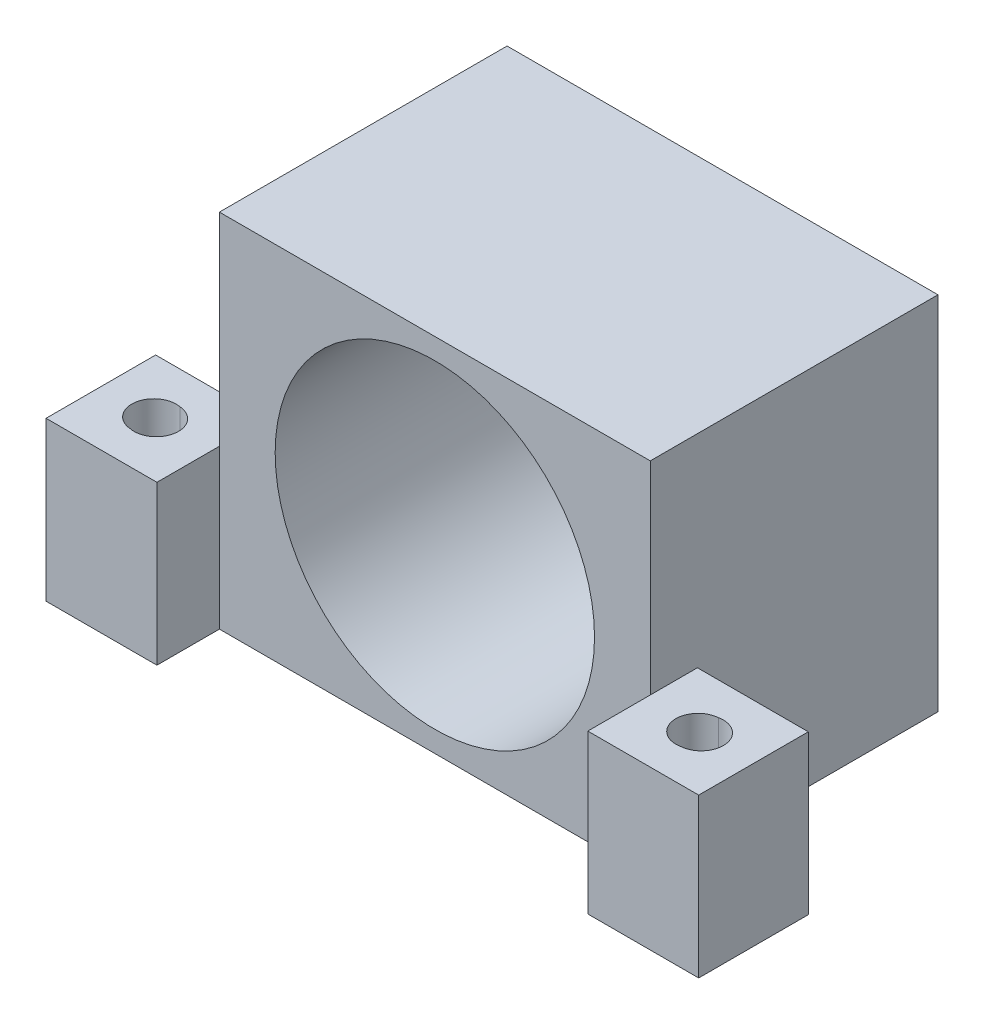
from build123d import *

# Parameters (mm, degrees)
SKETCH1_W                = 34
SKETCH1_H                = 28.5
BOSS_EXTRUDE1_DEPTH      = 22.7
SKETCH3_R                = 12.6
CUT_EXTRUDE1_DEPTH       = 21
SKETCH5_R                = 1.625
SKETCH5_R_2              = 3.75
CUT_EXTRUDE2_DEPTH       = 31.546071761
BOSS_EXTRUDE2_DEPTH      = 4.93
BOSS_EXTRUDE2_DEPTH_BACK = 3.72
SKETCH7_W                = 8.75
SKETCH7_H                = 12.5
SKETCH8_R                = 1.75
CUT_EXTRUDE3_DEPTH       = 42.018037496
SKETCH9_R                = 3.25
CUT_EXTRUDE4_DEPTH       = 3.175
SKETCH14_R               = 1.75
CUT_EXTRUDE8_DEPTH       = 50


with BuildPart() as part:
    # Sketch1 → Boss-Extrude1 (new body)
    with BuildSketch(Plane.XY):
        Rectangle(SKETCH1_W, SKETCH1_H)
    extrude(amount=BOSS_EXTRUDE1_DEPTH)

    # Sketch3 → Cut-Extrude1 (cut)
    with BuildSketch(Plane.XY.offset(22.7)):
        Circle(SKETCH3_R)
    extrude(amount=-CUT_EXTRUDE1_DEPTH, mode=Mode.SUBTRACT)

    # Sketch5 → Cut-Extrude2 (cut, through all)
    with BuildSketch(Plane.XY.offset(1.7)):
        with Locations((6.01040764, 6.01040764)):
            Circle(SKETCH5_R)
        with Locations((-6.01040764, 6.01040764)):
            Circle(SKETCH5_R)
        with Locations((6.01040764, -6.01040764)):
            Circle(SKETCH5_R)
        with Locations((-6.01040764, -6.01040764)):
            Circle(SKETCH5_R)
        Circle(SKETCH5_R_2)
    extrude(amount=-CUT_EXTRUDE2_DEPTH, mode=Mode.SUBTRACT)

    # Sketch7 → Boss-Extrude2 (add, two sides: drawn at the far end of the back side and taken through both)
    with BuildSketch(Plane.XY.offset(22.7).offset(-BOSS_EXTRUDE2_DEPTH_BACK)):
        with Locations((-21.375, -8)):
            Rectangle(SKETCH7_W, SKETCH7_H)
        with Locations((21.375, -8)):
            Rectangle(SKETCH7_W, SKETCH7_H)
    extrude(amount=BOSS_EXTRUDE2_DEPTH + BOSS_EXTRUDE2_DEPTH_BACK)

    # Sketch8 → Cut-Extrude3 (cut, through all)
    with BuildSketch(Plane(origin=(0, -1.75, 0), x_dir=(1, 0, 0), z_dir=(0, 1, 0))):
        with Locations(Location((21.375, -23.305, 0), (0, 0, 180))):
            Circle(SKETCH8_R)
        with Locations(Location((-21.375, -23.305, 0), (0, 0, 180))):
            Circle(SKETCH8_R)
    extrude(amount=-CUT_EXTRUDE3_DEPTH, mode=Mode.SUBTRACT)

    # Sketch9 → Cut-Extrude4 (cut)
    with BuildSketch(Plane.XZ.offset(14.25)):
        with Locations((-21.375, 23.305)):
            Circle(SKETCH9_R)
        with Locations((21.375, 23.305)):
            Circle(SKETCH9_R)
    extrude(amount=-CUT_EXTRUDE4_DEPTH, mode=Mode.SUBTRACT)

    # Cut-Extrude5 cone 1 section (through the dimple's axis) → Cut-Extrude5 (revolve, cut)
    with BuildSketch(Plane(origin=(-6.01040764, 6.01040764, 0), x_dir=(0, 1, 0), z_dir=(1, 0, 0))):
        Polygon((0, 0), (2.8, 0), (0, 2.8), align=None)
    revolve(axis=Axis((-6.01040764, 6.01040764, 0), (0, 0, 1)), mode=Mode.SUBTRACT)

    # Cut-Extrude5 cone 2 section (through the dimple's axis) → Cut-Extrude5 cone 2 (revolve, cut)
    with BuildSketch(Plane(origin=(-6.01040764, -6.01040764, 0), x_dir=(0, 1, 0), z_dir=(1, 0, 0))):
        Polygon((0, 0), (2.8, 0), (0, 2.8), align=None)
    revolve(axis=Axis((-6.01040764, -6.01040764, 0), (0, 0, 1)), mode=Mode.SUBTRACT)

    # Cut-Extrude5 cone 3 section (through the dimple's axis) → Cut-Extrude5 cone 3 (revolve, cut)
    with BuildSketch(Plane(origin=(6.01040764, -6.01040764, 0), x_dir=(0, 1, 0), z_dir=(1, 0, 0))):
        Polygon((0, 0), (2.8, 0), (0, 2.8), align=None)
    revolve(axis=Axis((6.01040764, -6.01040764, 0), (0, 0, 1)), mode=Mode.SUBTRACT)

    # Cut-Extrude5 cone 4 section (through the dimple's axis) → Cut-Extrude5 cone 4 (revolve, cut)
    with BuildSketch(Plane(origin=(6.01040764, 6.01040764, 0), x_dir=(0, 1, 0), z_dir=(1, 0, 0))):
        Polygon((0, 0), (2.8, 0), (0, 2.8), align=None)
    revolve(axis=Axis((6.01040764, 6.01040764, 0), (0, 0, 1)), mode=Mode.SUBTRACT)

    # Sketch14 → Cut-Extrude8 (cut)
    with BuildSketch(Plane(origin=(132.323959999, 1.25, 25.756345109), x_dir=(1, 0, 0), z_dir=(0, 1, 0))):
        with Locations((-110.733959999, 2.481345109)):
            Circle(SKETCH14_R)
        with Locations((-153.913959999, 2.481345109)):
            Circle(SKETCH14_R)
    extrude(amount=-CUT_EXTRUDE8_DEPTH, mode=Mode.SUBTRACT)


solid = part.part
